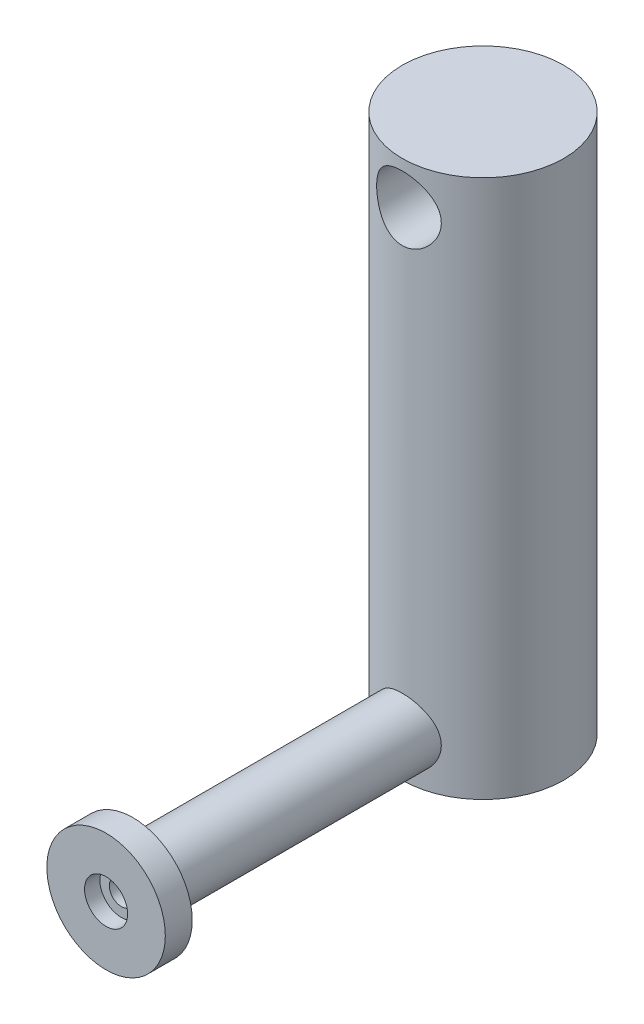
from build123d import *

# Parameters (mm, degrees)
SKETCH1_R                            = 15
BOSS_EXTRUDE1_DEPTH                  = 100
SKETCH2_R                            = 6
BOSS_EXTRUDE2_DEPTH                  = 50
BOSS_EXTRUDE2_DIRECTION_2_REACH      = 107.475
BOSS_EXTRUDE2_DIRECTION_2_END_RADIUS = 15
SKETCH3_R                            = 6
CUT_EXTRUDE1_DEPTH                   = 121.208152856
CUT_EXTRUDE1_DEPTH_BACK              = 121.208152856
SKETCH4_R                            = 11
BOSS_EXTRUDE3_DEPTH                  = 5
SKETCH5_R                            = 4
CUT_EXTRUDE2_DEPTH                   = 2.85
SKETCH6_R                            = 2.25
CUT_EXTRUDE3_DEPTH                   = 2.5


with BuildPart() as part:
    # Sketch1 → Boss-Extrude1 (new body)
    with BuildSketch(Plane(origin=(0, 0, 0), x_dir=(1, 0, 0), z_dir=(0, 1, 0))):
        with Locations(Location((0, 0, 0), (0, 0, 270))):
            Circle(SKETCH1_R)
    extrude(amount=BOSS_EXTRUDE1_DEPTH)

    # Sketch3 → Cut-Extrude1 (cut, two sides)
    with BuildSketch(Plane.XY) as cut_extrude1_sk:
        with Locations(Location((0, 92, 0), (0, 0, 90.000000001))):
            Circle(SKETCH3_R)
    extrude(amount=CUT_EXTRUDE1_DEPTH, mode=Mode.SUBTRACT)
    extrude(cut_extrude1_sk.sketch, amount=-CUT_EXTRUDE1_DEPTH_BACK, mode=Mode.SUBTRACT)


with BuildPart() as body_2:
    # Sketch2 → Boss-Extrude2 (new body)
    with BuildSketch(Plane.XY.offset(15)):
        with Locations((0, 8)):
            Circle(SKETCH2_R)
    extrude(amount=BOSS_EXTRUDE2_DEPTH)

    # Boss-Extrude2 direction 2: up to this cylinder (the profile starts outside it)
    boss_extrude2_direction_2_end = Plane(origin=(0, 8, 0), z_dir=(0, -1, 0)) * Cylinder(BOSS_EXTRUDE2_DIRECTION_2_END_RADIUS, 245.95, mode=Mode.PRIVATE)
    # Sketch2 → Boss-Extrude2 direction 2 (add, up to the surface)
    with BuildSketch(Plane.XY.offset(15), mode=Mode.PRIVATE) as boss_extrude2_direction_2_sk1:
        with Locations((0, 8)):
            Circle(SKETCH2_R)
    boss_extrude2_direction_2_tool1 = extrude(boss_extrude2_direction_2_sk1.sketch, amount=-BOSS_EXTRUDE2_DIRECTION_2_REACH, mode=Mode.PRIVATE) - boss_extrude2_direction_2_end
    add(boss_extrude2_direction_2_tool1.solids().sort_by_distance((0, 8, 15))[0])
    add(boss_extrude2_direction_2_tool1.solids().sort_by_distance((0, 8, 15))[1])

    # Sketch4 → Boss-Extrude3 (add)
    with BuildSketch(Plane.XY.offset(65)):
        with Locations((0, 8)):
            Circle(SKETCH4_R)
    extrude(amount=BOSS_EXTRUDE3_DEPTH)

    # Sketch5 → Cut-Extrude2 (cut)
    with BuildSketch(Plane.XY.offset(70)):
        with Locations((0, 8)):
            Circle(SKETCH5_R)
    extrude(amount=-CUT_EXTRUDE2_DEPTH, mode=Mode.SUBTRACT)

    # Sketch6 → Cut-Extrude3 (cut)
    with BuildSketch(Plane.XY.offset(67.15)):
        with Locations((0, 8)):
            Circle(SKETCH6_R)
    extrude(amount=-CUT_EXTRUDE3_DEPTH, mode=Mode.SUBTRACT)


solid = Compound([part.part, body_2.part])
